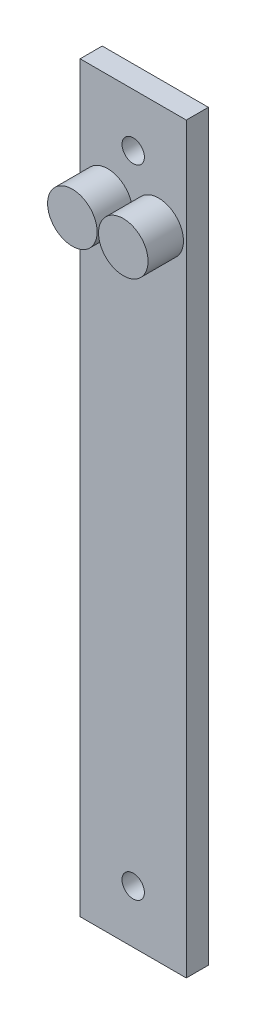
from build123d import *

# Parameters (mm, degrees)
SKETCH1_W                = 38.1
SKETCH1_H                = 266.7
BOSS_EXTRUDE1_DEPTH      = 7.9375
O_0_316_DIAMETER_HOLE1_D = 8.0264
SKETCH4_R                = 8.89
BOSS_EXTRUDE2_DEPTH      = 12.7


with BuildPart() as part:
    # Sketch1 → Boss-Extrude1 (new body)
    with BuildSketch(Plane.XY):
        Rectangle(SKETCH1_W, SKETCH1_H)
    extrude(amount=BOSS_EXTRUDE1_DEPTH)

    # O (0.316) Diameter Hole1 (through all)
    with Locations(Plane.XY.offset(7.9375)):
        with Locations((0, 114.3)):
            o_0_316_diameter_hole1 = Hole(O_0_316_DIAMETER_HOLE1_D / 2)

    # Mirror1: O (0.316) Diameter Hole1 across plane
    add(o_0_316_diameter_hole1.mirror(Plane.ZX), mode=Mode.SUBTRACT)

    # Sketch4 → Boss-Extrude2 (add)
    with BuildSketch(Plane.XY.offset(7.9375)):
        with Locations((-9.144, 95.25)):
            Circle(SKETCH4_R)
        with Locations((9.144, 95.25)):
            Circle(SKETCH4_R)
    extrude(amount=BOSS_EXTRUDE2_DEPTH)


solid = part.part
